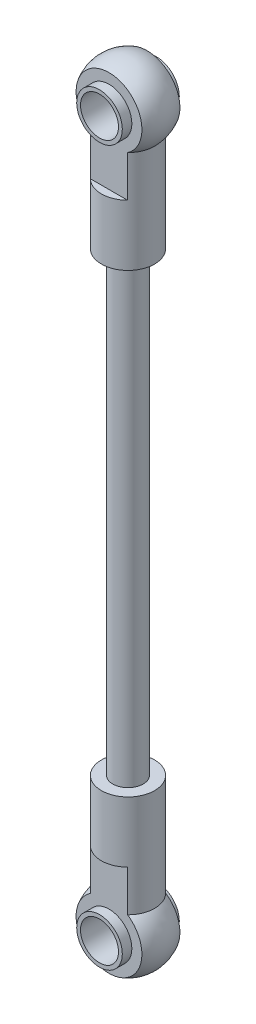
from build123d import *

# Parameters (mm, degrees)
SKETCH2_R               = 2.5
CUT_EXTRUDE1_DEPTH      = 6
CUT_EXTRUDE1_DEPTH_BACK = 6
SKETCH4_W               = 12
SKETCH4_H               = 18
CUT_EXTRUDE2_DEPTH      = 1.830127
SKETCH3_R               = 3
SKETCH3_R_2             = 2.5
EXTRUDE_THIN1_DEPTH     = 3.75
SKETCH5_R               = 2
BOSS_EXTRUDE1_DEPTH     = 30


with BuildPart() as part:
    # Sketch1 → Revolve1 (revolve)
    with BuildSketch(Plane.XY):
        with BuildLine():
            Line((0, 0), (0, -7))
            Line((0, -7), (1.75, -7))
            Line((1.75, -7), (1.75, -17))
            Line((1.75, -17), (3.5, -17))
            Line((3.5, -17), (3.5, -3.570714214))
            ThreePointArc((3.5, -3.570714214), (4.628907596, 1.890294809), (0, 5))
            Line((0, 5), (0, 0))
        make_face()
    revolve(axis=Axis((0, 0, 0), (0, 1, 0)))

    # Sketch2 → Cut-Extrude1 (cut, two sides)
    with BuildSketch(Plane.XY) as cut_extrude1_sk:
        Circle(SKETCH2_R)
    extrude(amount=CUT_EXTRUDE1_DEPTH, mode=Mode.SUBTRACT)
    extrude(cut_extrude1_sk.sketch, amount=-CUT_EXTRUDE1_DEPTH_BACK, mode=Mode.SUBTRACT)

    # Sketch4 → Cut-Extrude2 (cut)
    with BuildSketch(Plane.XY.offset(2.5)):
        Rectangle(SKETCH4_W, SKETCH4_H)
    cut_extrude2 = extrude(amount=CUT_EXTRUDE2_DEPTH, mode=Mode.SUBTRACT)

    # Mirror1: Cut-Extrude2 across plane
    add(cut_extrude2.mirror(Plane.XY), mode=Mode.SUBTRACT)

    # Sketch3 → Extrude-Thin1 (add, symmetric)
    with BuildSketch(Plane.XY):
        Circle(SKETCH3_R)
        Circle(SKETCH3_R_2, mode=Mode.SUBTRACT)
    extrude(amount=EXTRUDE_THIN1_DEPTH, both=True)


with BuildPart() as body_2:
    # Mirror3: mirrored copy
    add(part.part.mirror(Plane(origin=(0, -47, 0), x_dir=(0, 0, 1), z_dir=(0, -1, 0))))


with BuildPart() as part_1:
    add(part.part)

    add(body_2.part)  # Boss-Extrude1 merges body 2
    # Sketch5 → Boss-Extrude1 (add, symmetric)
    with BuildSketch(Plane(origin=(0, -47, 0), x_dir=(-1, 0, 0), z_dir=(0, -1, 0))):
        Circle(SKETCH5_R)
    extrude(amount=BOSS_EXTRUDE1_DEPTH, both=True)


solid = part_1.part
